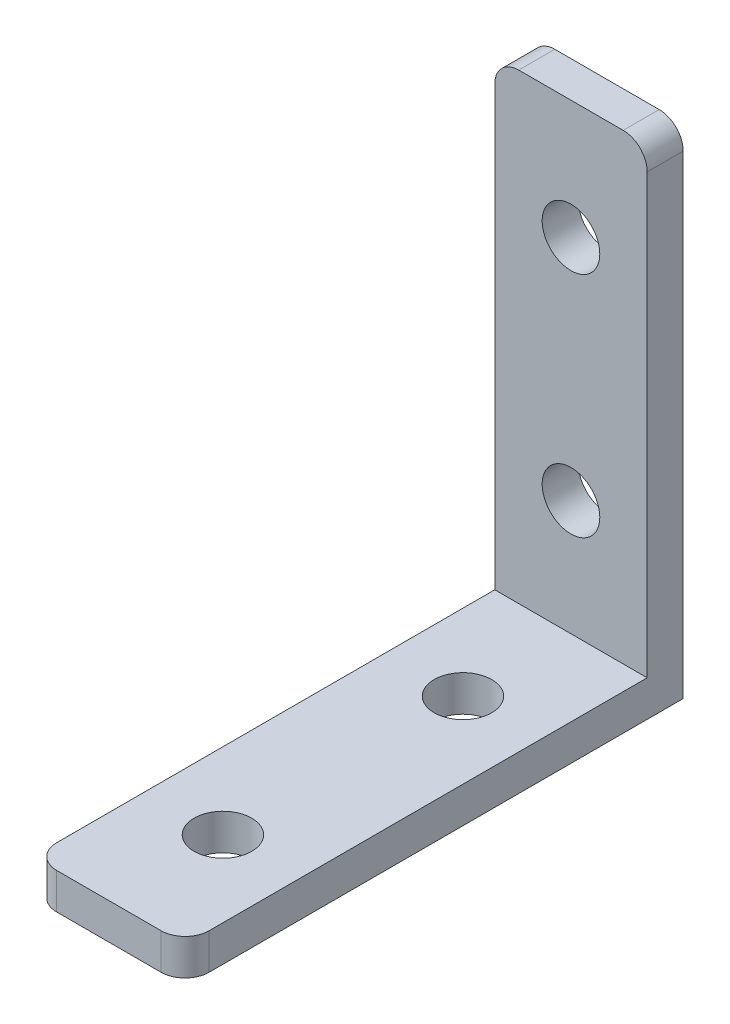
from build123d import *

# Parameters (mm, degrees)
ESBO_O1_W                = 12.7
ESBO_O1_H                = 41.5
ESBO_O1_R                = 2.4
RESSALTO_EXTRUS_O1_DEPTH = 3
ESBO_O2_W                = 12.7
ESBO_O2_H                = 3
RESSALTO_EXTRUS_O2_DEPTH = 38.5
ESBO_O3_R                = 2.4
CORTE_EXTRUS_O1_DEPTH    = 41.5
FILETE1_R                = 2


with BuildPart() as part:
    # Esboço1 → Ressalto-extrusão1 (new body)
    with BuildSketch(Plane.XY):
        Rectangle(ESBO_O1_W, ESBO_O1_H)
        with Locations((0, 10.85)):
            Circle(ESBO_O1_R, mode=Mode.SUBTRACT)
        with Locations((0, -8.15)):
            Circle(ESBO_O1_R, mode=Mode.SUBTRACT)
    extrude(amount=RESSALTO_EXTRUS_O1_DEPTH)

    # Esboço2 → Ressalto-extrusão2 (add)
    with BuildSketch(Plane.XY.offset(3)):
        with Locations((0, -19.25)):
            Rectangle(ESBO_O2_W, ESBO_O2_H)
    extrude(amount=RESSALTO_EXTRUS_O2_DEPTH)

    # Esboço3 → Corte-extrusão1 (cut)
    with BuildSketch(Plane(origin=(0, -17.75, 0), x_dir=(1, 0, 0), z_dir=(0, 1, 0))):
        with Locations((0, -12)):
            Circle(ESBO_O3_R)
        with Locations((0, -32)):
            Circle(ESBO_O3_R)
    extrude(amount=-CORTE_EXTRUS_O1_DEPTH, mode=Mode.SUBTRACT)

    # Filete1
    filete1_edges = [part.edges().sort_by_distance(p)[0] for p in [
        (6.35, -19.25, 41.5),
        (-6.35, -19.25, 41.5),
        (-6.35, 20.75, 1.5),
        (6.35, 20.75, 1.5),
    ]]
    fillet(filete1_edges, radius=FILETE1_R)


solid = part.part
